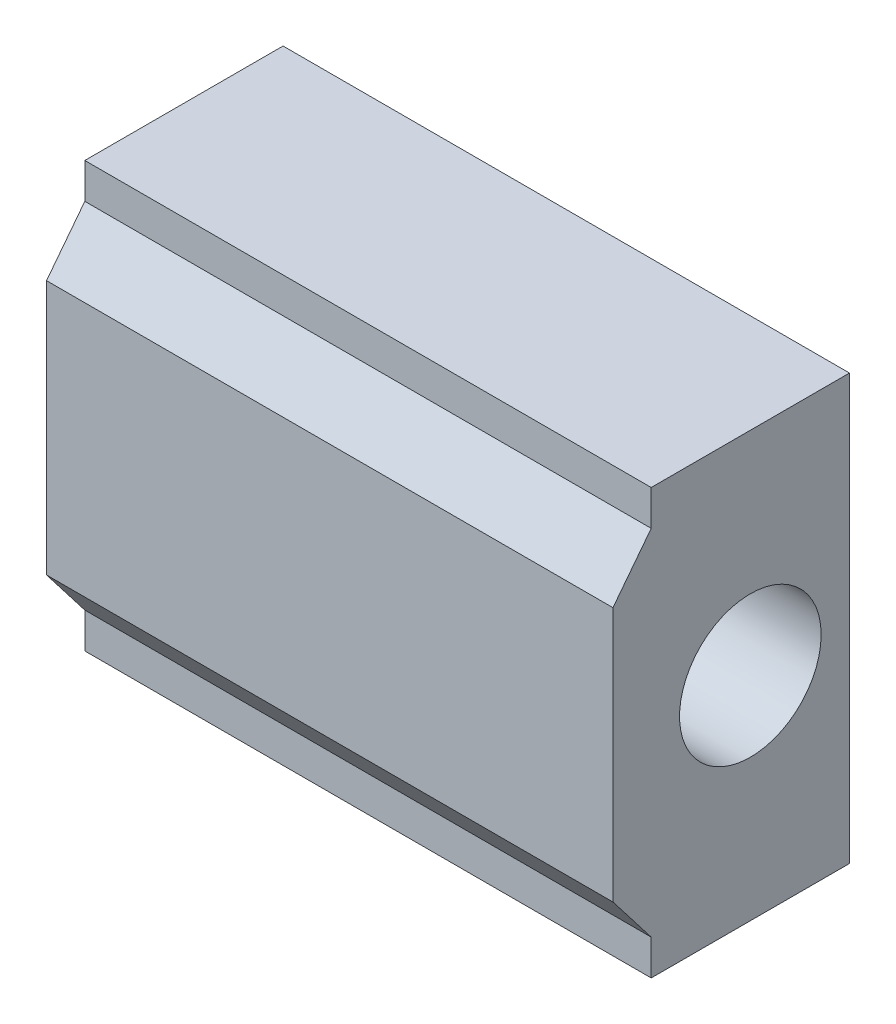
from build123d import *

# Parameters (mm, degrees)
SKETCH1_R           = 5
BOSS_EXTRUDE1_DEPTH = 40


with BuildPart() as part:
    # Sketch1 → Boss-Extrude1 (new body)
    with BuildSketch(Plane(origin=(0, 0, 0), x_dir=(0, 0, -1), z_dir=(1, 0, 0))):
        Polygon((-9.702519419, -9), (-9.702519419, 9), (-7, 12.5), (-7, 15), (7, 15), (7, -15), (-7, -15), (-7, -12.5), align=None)
        Circle(SKETCH1_R, mode=Mode.SUBTRACT)
    extrude(amount=BOSS_EXTRUDE1_DEPTH)


solid = part.part
